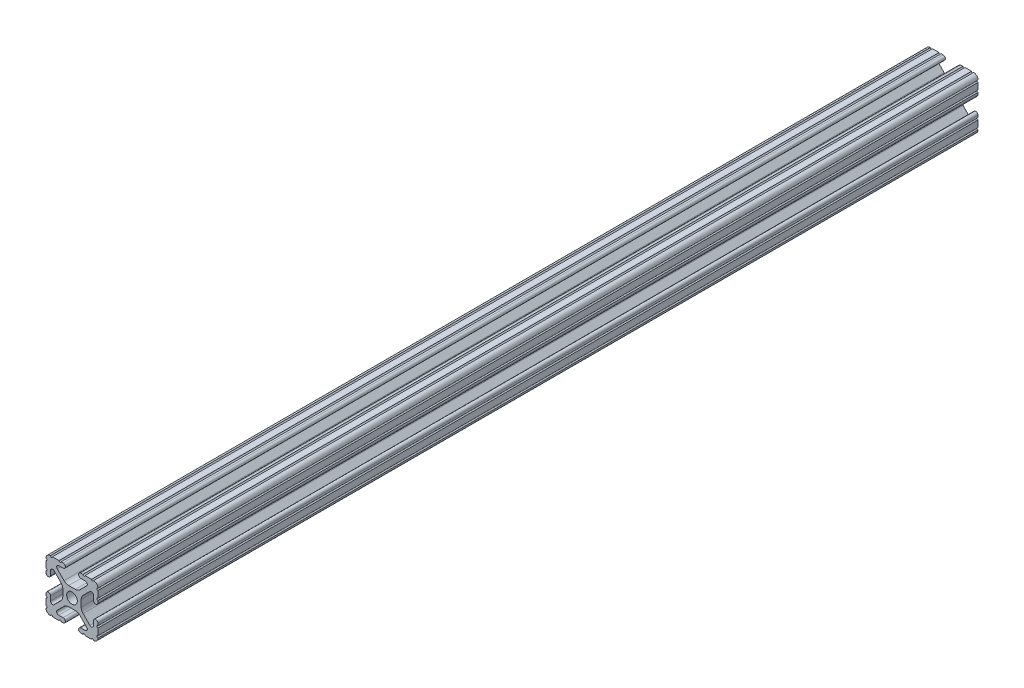
from build123d import *

# Parameters (mm, degrees)
SKETCH1_R           = 2.6035
BOSS_EXTRUDE1_DEPTH = 215.10625


with BuildPart() as part:
    # Sketch1 → Boss-Extrude1 (new body, symmetric)
    with BuildSketch(Plane(origin=(0, 0, -450.85), x_dir=(-1, 0, 0), z_dir=(0, 0, -1))):
        with BuildLine():
            Line((12.7, -9.5504), (12.7, -6.3330836))
            ThreePointArc((12.7, -6.3330836), (12.192, -5.8250836), (12.7, -5.3170836))
            Line((12.7, -5.3170836), (12.7, -4.3434))
            ThreePointArc((12.7, -4.3434), (11.5951, -3.2385), (10.4902, -4.3434))
            Line((10.4902, -4.3434), (10.4902, -6.474794456))
            ThreePointArc((10.4902, -6.474794456), (9.863006367, -7.413456061), (8.75577951, -7.193214945))
            Line((8.75577951, -7.193214945), (5.42573597, -3.863171405))
            ThreePointArc((5.42573597, -3.863171405), (4.737482484, -2.833127272), (4.4958, -1.618107374))
            Line((4.4958, -1.618107374), (4.4958, 1.618107374))
            ThreePointArc((4.4958, 1.618107374), (4.737482484, 2.833127272), (5.42573597, 3.863171405))
            Line((5.42573597, 3.863171405), (8.75577951, 7.193214945))
            ThreePointArc((8.75577951, 7.193214945), (9.863006367, 7.413456061), (10.4902, 6.474794456))
            Line((10.4902, 6.474794456), (10.4902, 4.343399971))
            ThreePointArc((10.4902, 4.343399971), (11.5951, 3.238499971), (12.7, 4.343399971))
            Line((12.7, 4.343399971), (12.7, 5.3170836))
            ThreePointArc((12.7, 5.3170836), (12.192, 5.8250836), (12.7, 6.3330836))
            Line((12.7, 6.3330836), (12.7, 9.5504))
            ThreePointArc((12.7, 9.5504), (12.192000006, 10.058323491), (12.699846982, 10.566399977))
            ThreePointArc((12.699846982, 10.566399977), (12.082522516, 12.082522516), (10.566399977, 12.699846982))
            ThreePointArc((10.566399977, 12.699846982), (10.058323491, 12.192000006), (9.5504, 12.7))
            Line((9.5504, 12.7), (6.3330836, 12.7))
            ThreePointArc((6.3330836, 12.7), (5.8250836, 12.192), (5.3170836, 12.7))
            Line((5.3170836, 12.7), (4.3434, 12.7))
            ThreePointArc((4.3434, 12.7), (3.2385, 11.5951), (4.3434, 10.4902))
            Line((4.3434, 10.4902), (6.474794456, 10.4902))
            ThreePointArc((6.474794456, 10.4902), (7.413456061, 9.863006367), (7.193214945, 8.75577951))
            Line((7.193214945, 8.75577951), (3.863171405, 5.42573597))
            ThreePointArc((3.863171405, 5.42573597), (2.833127272, 4.737482484), (1.618107374, 4.4958))
            Line((1.618107374, 4.4958), (-1.618107374, 4.4958))
            ThreePointArc((-1.618107374, 4.4958), (-2.833127272, 4.737482484), (-3.863171405, 5.42573597))
            Line((-3.863171405, 5.42573597), (-7.193214945, 8.75577951))
            ThreePointArc((-7.193214945, 8.75577951), (-7.413456061, 9.863006367), (-6.474794456, 10.4902))
            Line((-6.474794456, 10.4902), (-4.343399971, 10.4902))
            ThreePointArc((-4.343399971, 10.4902), (-3.238499971, 11.5951), (-4.343399971, 12.7))
            Line((-4.343399971, 12.7), (-5.3170836, 12.7))
            ThreePointArc((-5.3170836, 12.7), (-5.8250836, 12.192), (-6.3330836, 12.7))
            Line((-6.3330836, 12.7), (-9.5504, 12.7))
            ThreePointArc((-9.5504, 12.7), (-10.058323491, 12.192000006), (-10.566399977, 12.699846982))
            ThreePointArc((-10.566399977, 12.699846982), (-12.082522516, 12.082522516), (-12.699846982, 10.566399977))
            ThreePointArc((-12.699846982, 10.566399977), (-12.192000006, 10.058323491), (-12.7, 9.5504))
            Line((-12.7, 9.5504), (-12.7, 6.3330836))
            ThreePointArc((-12.7, 6.3330836), (-12.192, 5.8250836), (-12.7, 5.3170836))
            Line((-12.7, 5.3170836), (-12.7, 4.3434))
            ThreePointArc((-12.7, 4.3434), (-11.5951, 3.2385), (-10.4902, 4.3434))
            Line((-10.4902, 4.3434), (-10.4902, 6.474794456))
            ThreePointArc((-10.4902, 6.474794456), (-9.863006367, 7.413456061), (-8.75577951, 7.193214945))
            Line((-8.75577951, 7.193214945), (-5.42573597, 3.863171405))
            ThreePointArc((-5.42573597, 3.863171405), (-4.737482484, 2.833127272), (-4.4958, 1.618107374))
            Line((-4.4958, 1.618107374), (-4.4958, -1.618107374))
            ThreePointArc((-4.4958, -1.618107374), (-4.737482484, -2.833127272), (-5.42573597, -3.863171405))
            Line((-5.42573597, -3.863171405), (-8.75577951, -7.193214945))
            ThreePointArc((-8.75577951, -7.193214945), (-9.863006367, -7.413456061), (-10.4902, -6.474794456))
            Line((-10.4902, -6.474794456), (-10.4902, -4.343399971))
            ThreePointArc((-10.4902, -4.343399971), (-11.5951, -3.238499971), (-12.7, -4.343399971))
            Line((-12.7, -4.343399971), (-12.7, -5.3170836))
            ThreePointArc((-12.7, -5.3170836), (-12.192, -5.8250836), (-12.7, -6.3330836))
            Line((-12.7, -6.3330836), (-12.7, -9.5504))
            ThreePointArc((-12.7, -9.5504), (-12.192000006, -10.058323491), (-12.699846982, -10.566399977))
            ThreePointArc((-12.699846982, -10.566399977), (-12.082522516, -12.082522516), (-10.566399977, -12.699846982))
            ThreePointArc((-10.566399977, -12.699846982), (-10.058323491, -12.192000006), (-9.5504, -12.7))
            Line((-9.5504, -12.7), (-6.3330836, -12.7))
            ThreePointArc((-6.3330836, -12.7), (-5.8250836, -12.192), (-5.3170836, -12.7))
            Line((-5.3170836, -12.7), (-4.3434, -12.7))
            ThreePointArc((-4.3434, -12.7), (-3.2385, -11.5951), (-4.3434, -10.4902))
            Line((-4.3434, -10.4902), (-6.474794456, -10.4902))
            ThreePointArc((-6.474794456, -10.4902), (-7.413456061, -9.863006367), (-7.193214945, -8.75577951))
            Line((-7.193214945, -8.75577951), (-3.863171405, -5.42573597))
            ThreePointArc((-3.863171405, -5.42573597), (-2.833127272, -4.737482484), (-1.618107374, -4.4958))
            Line((-1.618107374, -4.4958), (1.618107374, -4.4958))
            ThreePointArc((1.618107374, -4.4958), (2.833127272, -4.737482484), (3.863171405, -5.42573597))
            Line((3.863171405, -5.42573597), (7.193214945, -8.75577951))
            ThreePointArc((7.193214945, -8.75577951), (7.413456061, -9.863006367), (6.474794456, -10.4902))
            Line((6.474794456, -10.4902), (4.343399971, -10.4902))
            ThreePointArc((4.343399971, -10.4902), (3.238499971, -11.5951), (4.343399971, -12.7))
            Line((4.343399971, -12.7), (5.3170836, -12.7))
            ThreePointArc((5.3170836, -12.7), (5.8250836, -12.192), (6.3330836, -12.7))
            Line((6.3330836, -12.7), (9.5504, -12.7))
            ThreePointArc((9.5504, -12.7), (10.058323491, -12.192000006), (10.566399977, -12.699846982))
            ThreePointArc((10.566399977, -12.699846982), (12.082522516, -12.082522516), (12.699846982, -10.566399977))
            ThreePointArc((12.699846982, -10.566399977), (12.192000006, -10.058323491), (12.7, -9.5504))
        make_face()
        Circle(SKETCH1_R, mode=Mode.SUBTRACT)
    extrude(amount=BOSS_EXTRUDE1_DEPTH, both=True)


solid = part.part
